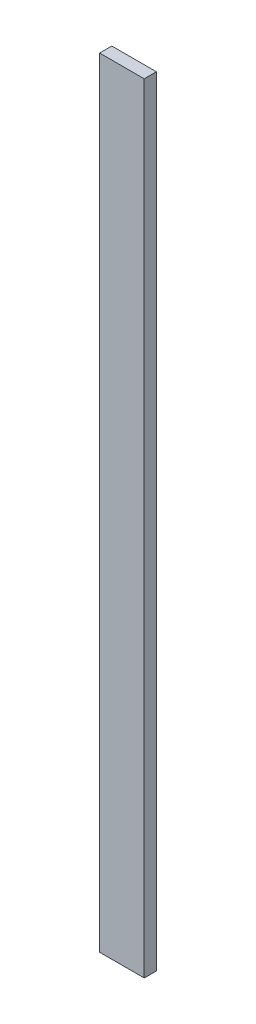
from build123d import *

# Parameters (mm, degrees)
SKETCH1_W           = 139.7
SKETCH1_H           = 38.1
BOSS_EXTRUDE1_DEPTH = 2438.4


with BuildPart() as part:
    # Sketch1 → Boss-Extrude1 (new body)
    with BuildSketch(Plane(origin=(0, 0, 0), x_dir=(1, 0, 0), z_dir=(0, 1, 0))):
        Rectangle(SKETCH1_W, SKETCH1_H)
    extrude(amount=BOSS_EXTRUDE1_DEPTH)


solid = part.part
